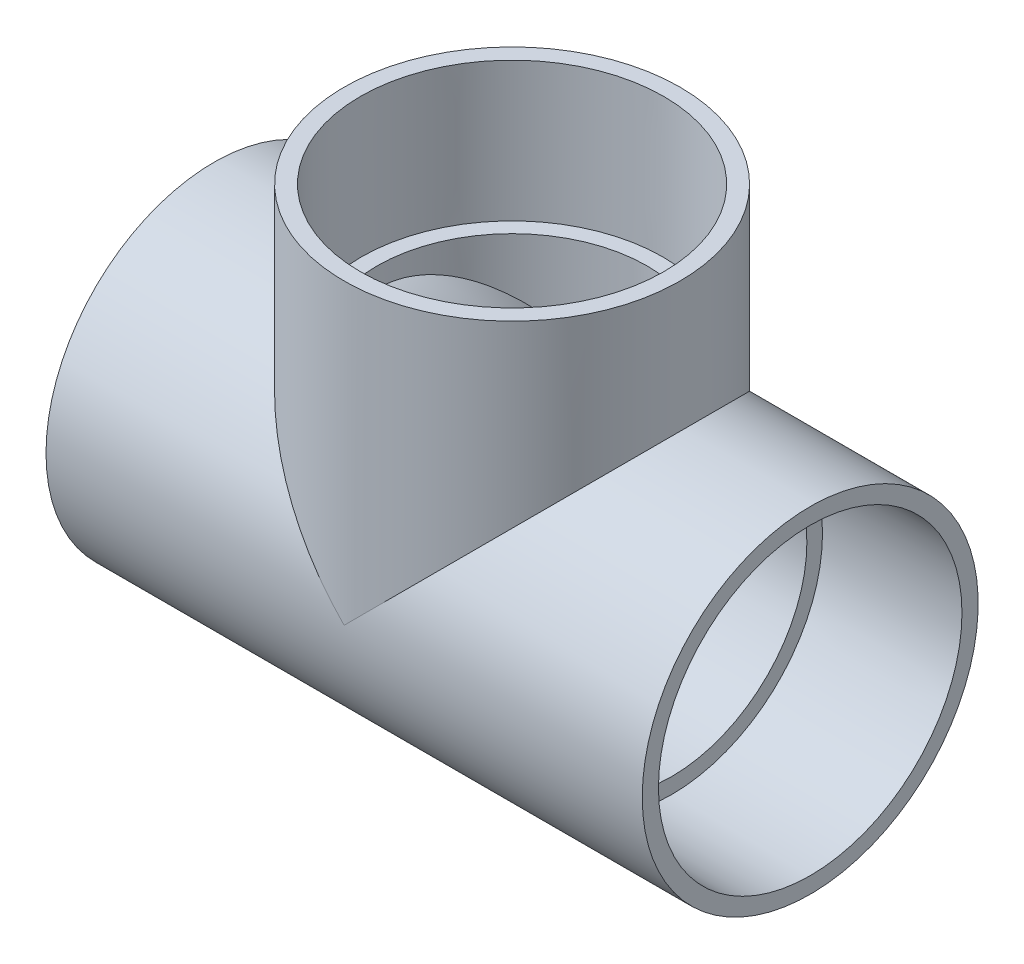
from build123d import *

# Parameters (mm, degrees)
BOSS_EXTRUDE1_DEPTH = 120.65
BOSS_EXTRUDE2_REACH = 125.825
SKETCH5_R           = 51.1302
CUT_EXTRUDE1_DEPTH  = 120.65
CUT_EXTRUDE2_START  = -60.325
SKETCH6_R           = 51.1302
CUT_EXTRUDE2_DEPTH  = 60.325


with BuildPart() as part:
    # Sketch1 → Revolve1 (revolve)
    with BuildSketch(Plane.XY):
        Polygon((-112.7125, -63.5), (-60.325, -63.5), (-60.325, -57.0357), (-112.7125, -57.3786), align=None)
    revolve(axis=Axis((-112.7125, 0, 0), (1, 0, 0)))


with BuildPart() as body_2:
    # Mirror1: mirrored copy
    add(part.part.mirror(Plane(origin=(0, 0, 0), x_dir=(0, 0, 1), z_dir=(1, 0, 0))))


with BuildPart() as body_3:
    # Sketch2 → Revolve2 (revolve)
    with BuildSketch(Plane.XY):
        Polygon((57.3786, 112.7125), (57.0357, 60.325), (63.5, 60.325), (63.5, 112.7125), align=None)
    revolve(axis=Axis((0, 0, 0), (0, 1, 0)))


with BuildPart() as part_1:
    add(part.part)

    add(body_2.part)  # Boss-Extrude1 merges body 2

    add(body_3.part)  # Boss-Extrude1 merges body 3
    # Sketch3 → Boss-Extrude1 (add)
    with BuildSketch(Plane(origin=(-60.325, 0, 0), x_dir=(0, 0, -1), z_dir=(1, 0, 0))):
        with BuildLine():
            Line((19.827868645, 60.325), (-19.827868645, 60.325))
            ThreePointArc((-19.827868645, 60.325), (0, -63.5), (19.827868645, 60.325))
        make_face()
    extrude(amount=BOSS_EXTRUDE1_DEPTH)

    # Sketch4 → Boss-Extrude2 (add, up to next)
    with BuildSketch(Plane.XZ.offset(-60.325), mode=Mode.PRIVATE) as boss_extrude2_sk1:
        with BuildLine():
            ThreePointArc((-60.325, -19.827868645), (0, -63.5), (60.325, -19.827868645))
            Line((60.325, -19.827868645), (-60.325, -19.827868645))
        make_face()
    boss_extrude2_tool1 = extrude(boss_extrude2_sk1.sketch, amount=BOSS_EXTRUDE2_REACH, mode=Mode.PRIVATE) - part_1.part
    add(boss_extrude2_tool1.solids().sort_by_distance((0, 60.325, -37.942294))[0])
    # Sketch4 → Boss-Extrude2 (add, up to next)
    with BuildSketch(Plane.XZ.offset(-60.325), mode=Mode.PRIVATE) as boss_extrude2_sk2:
        with BuildLine():
            ThreePointArc((60.325, 19.827868645), (0, 63.5), (-60.325, 19.827868645))
            Line((-60.325, 19.827868645), (60.325, 19.827868645))
        make_face()
    boss_extrude2_tool2 = extrude(boss_extrude2_sk2.sketch, amount=BOSS_EXTRUDE2_REACH, mode=Mode.PRIVATE) - part_1.part
    add(boss_extrude2_tool2.solids().sort_by_distance((0, 60.325, 37.942294))[0])

    # Sketch5 → Cut-Extrude1 (cut)
    with BuildSketch(Plane.ZY.offset(60.325)):
        Circle(SKETCH5_R)
    extrude(amount=-CUT_EXTRUDE1_DEPTH, mode=Mode.SUBTRACT)

    # Sketch6 → Cut-Extrude2 (cut)
    with BuildSketch(Plane(origin=(0, 60.325, 0), x_dir=(1, 0, 0), z_dir=(0, 1, 0)).offset(CUT_EXTRUDE2_START)):
        Circle(SKETCH6_R)
    extrude(amount=CUT_EXTRUDE2_DEPTH, mode=Mode.SUBTRACT)


solid = part_1.part
